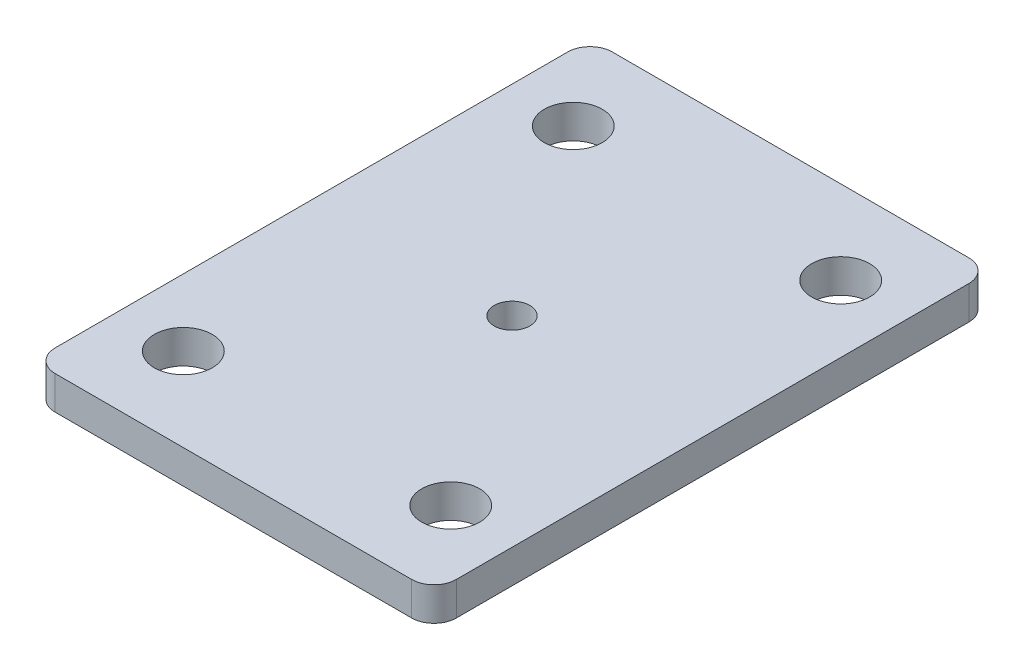
from build123d import *

# Parameters (mm, degrees)
SKETCH_1_W          = 36
SKETCH_1_H          = 50
SKETCH_1_R          = 2.6
EXTRUDE_1_DEPTH     = 3
FILLET_1_R          = 2
SKETCH_6_R          = 1.6
CUT_EXTRUDE_5_DEPTH = 10


with BuildPart() as part:
    # 草图1 → 凸台-拉伸1 (new body)
    with BuildSketch(Plane(origin=(0, 0, 0), x_dir=(1, 0, 0), z_dir=(0, 1, 0))):
        Rectangle(SKETCH_1_W, SKETCH_1_H)
        with Locations((-12, 17.5)):
            Circle(SKETCH_1_R, mode=Mode.SUBTRACT)
        with Locations((12, 17.5)):
            Circle(SKETCH_1_R, mode=Mode.SUBTRACT)
        with Locations((-12, -17.5)):
            Circle(SKETCH_1_R, mode=Mode.SUBTRACT)
        with Locations((12, -17.5)):
            Circle(SKETCH_1_R, mode=Mode.SUBTRACT)
    extrude(amount=EXTRUDE_1_DEPTH)

    # 圆角1
    fillet_1_edges = [part.edges().sort_by_distance(p)[0] for p in [
        (18, 1.5, 25),
        (-18, 1.5, 25),
        (-18, 1.5, -25),
        (18, 1.5, -25),
    ]]
    fillet(fillet_1_edges, radius=FILLET_1_R)

    # 草图6 → 切除-拉伸5 (cut)
    with BuildSketch(Plane(origin=(0, 3, 0), x_dir=(1, 0, 0), z_dir=(0, 1, 0))):
        Circle(SKETCH_6_R)
    extrude(amount=-CUT_EXTRUDE_5_DEPTH, mode=Mode.SUBTRACT)


solid = part.part
